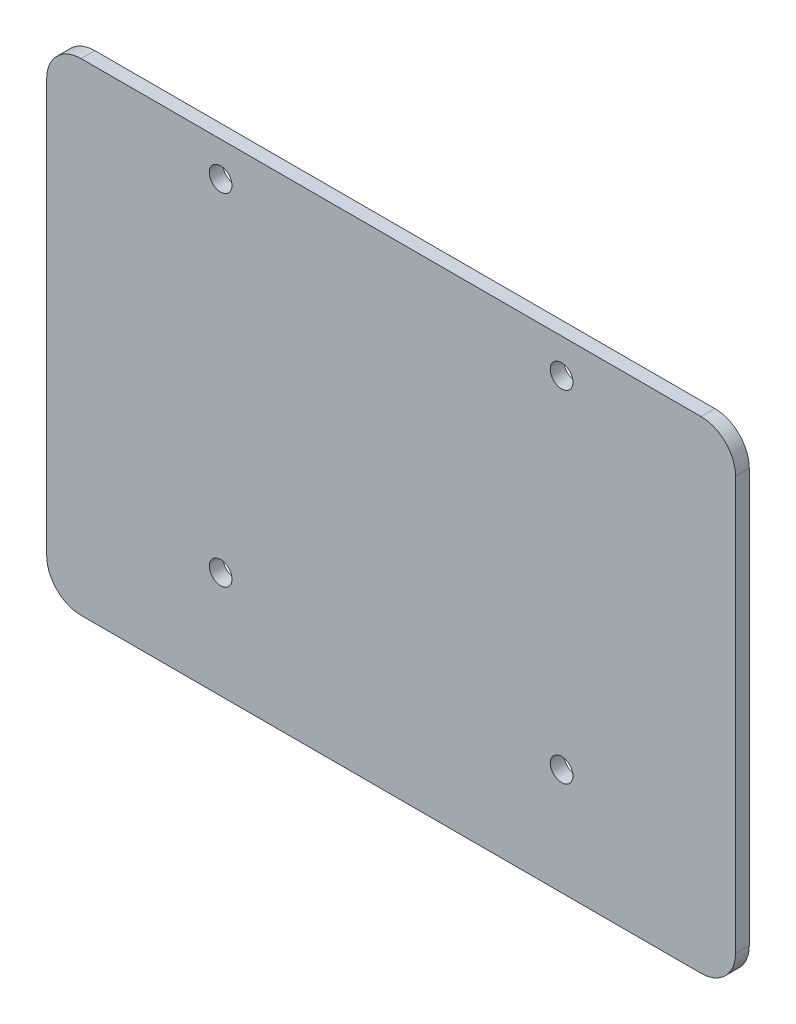
from build123d import *

# Parameters (mm, degrees)
SKETCH_1_W      = 100
SKETCH_1_H      = 70
SKETCH_1_R      = 1.65
EXTRUDE_1_DEPTH = 2
FILLET_1_R      = 5


with BuildPart() as part:
    # 草图1 → 凸台-拉伸1 (new body)
    with BuildSketch(Plane.XY):
        with Locations((50, 35)):
            Rectangle(SKETCH_1_W, SKETCH_1_H)
        with Locations((25.25, 65)):
            Circle(SKETCH_1_R, mode=Mode.SUBTRACT)
        with Locations((25.25, 15.5)):
            Circle(SKETCH_1_R, mode=Mode.SUBTRACT)
        with Locations((74.75, 15.5)):
            Circle(SKETCH_1_R, mode=Mode.SUBTRACT)
        with Locations((74.75, 65)):
            Circle(SKETCH_1_R, mode=Mode.SUBTRACT)
    extrude(amount=EXTRUDE_1_DEPTH)

    # 圆角1
    fillet_1_edges = [part.edges().sort_by_distance(p)[0] for p in [
        (0, 70, 1),
        (100, 70, 1),
        (100, 0, 1),
        (0, 0, 1),
    ]]
    fillet(fillet_1_edges, radius=FILLET_1_R)


solid = part.part
